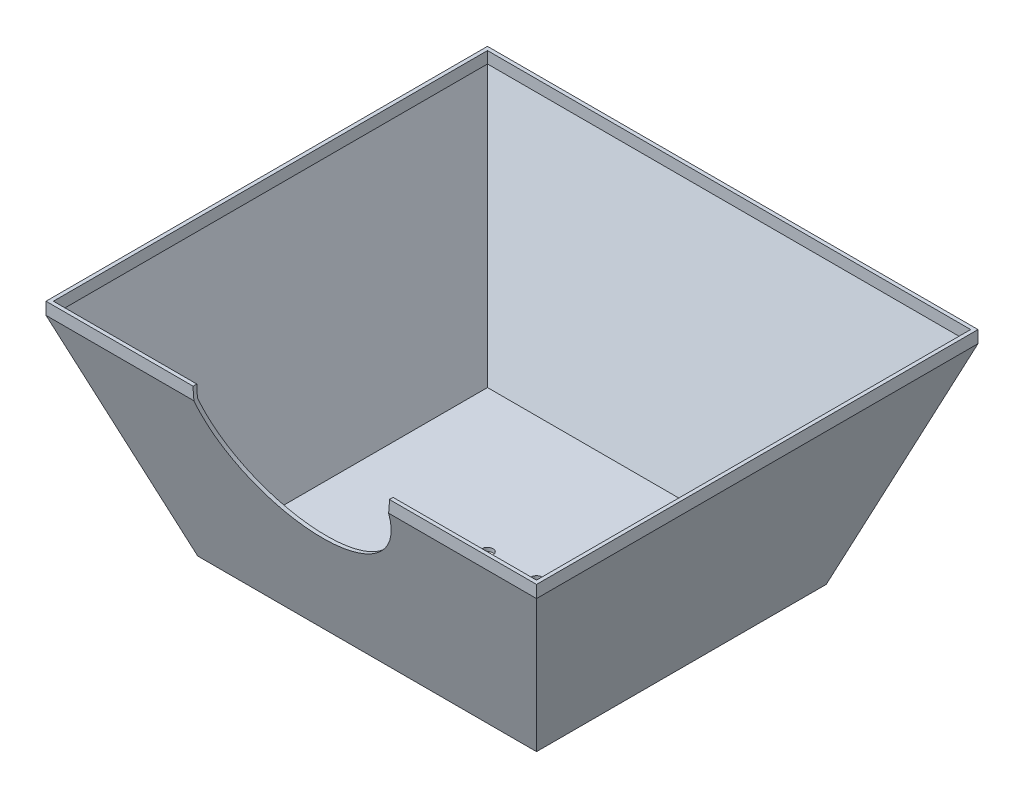
from build123d import *

# Parameters (mm, degrees)
SKETCH1_W               = 200
SKETCH1_H               = 180
BOSS_EXTRUDE1_DEPTH     = 90
CUT_EXTRUDE1_DEPTH      = 1
CUT_EXTRUDE1_DEPTH_BACK = 181
CUT_EXTRUDE2_DEPTH      = 201
SHELL1_T                = -1.5
SKETCH6_R               = 2.25
HINGE_HOLES_DEPTH       = 2.5
CUT_EXTRUDE4_DEPTH      = 50


with BuildPart() as part:
    # Sketch1 → Boss-Extrude1 (new body)
    with BuildSketch(Plane(origin=(0, 0, 0), x_dir=(1, 0, 0), z_dir=(0, 1, 0))):
        with Locations((100, 90)):
            Rectangle(SKETCH1_W, SKETCH1_H)
    extrude(amount=BOSS_EXTRUDE1_DEPTH)

    # Sketch4 → Cut-Extrude1 (cut, two sides)
    with BuildSketch(Plane.XY) as cut_extrude1_sk:
        Polygon((0, 85), (30.937469913, 0), (0, 0), align=None)
        Polygon((200, 85), (200, 0), (169.062530087, 0), align=None)
    extrude(amount=CUT_EXTRUDE1_DEPTH, mode=Mode.SUBTRACT)
    extrude(cut_extrude1_sk.sketch, amount=-CUT_EXTRUDE1_DEPTH_BACK, mode=Mode.SUBTRACT)

    # Sketch5 → Cut-Extrude2 (cut, through all)
    with BuildSketch(Plane.ZY):
        Polygon((-180, 85), (-149.062530087, 0), (-180, 0), align=None)
        Polygon((0, 85), (-30.937469913, 0), (0, 0), align=None)
    extrude(amount=-CUT_EXTRUDE2_DEPTH, mode=Mode.SUBTRACT)

    # Shell1
    shell1_openings = [part.faces().sort_by_distance(p)[0] for p in [
        (100, 90, -90),
    ]]
    offset(amount=SHELL1_T, openings=shell1_openings, kind=Kind.INTERSECTION)

    # Sketch6 → Hinge-Holes (cut, through all)
    with BuildSketch(Plane(origin=(0, 1.5, 0), x_dir=(1, 0, 0), z_dir=(0, 1, 0))):
        with Locations((90, 90)):
            Circle(SKETCH6_R)
        with Locations((110, 90)):
            Circle(SKETCH6_R)
    extrude(amount=-HINGE_HOLES_DEPTH, mode=Mode.SUBTRACT)

    # Sketch7 → Cut-Extrude4 (cut)
    with BuildSketch(Plane.XY):
        with BuildLine():
            Line((139.686269666, 85), (60.313730334, 85))
            ThreePointArc((60.313730334, 85), (100, 50), (139.686269666, 85))
        make_face()
        with BuildLine():
            Line((140, 90), (60, 90))
            ThreePointArc((60, 90), (60.078509631, 87.495083498), (60.313730334, 85))
            Line((60.313730334, 85), (139.686269666, 85))
            ThreePointArc((139.686269666, 85), (139.921490369, 87.495083498), (140, 90))
        make_face()
    extrude(amount=-CUT_EXTRUDE4_DEPTH, mode=Mode.SUBTRACT)


solid = part.part
